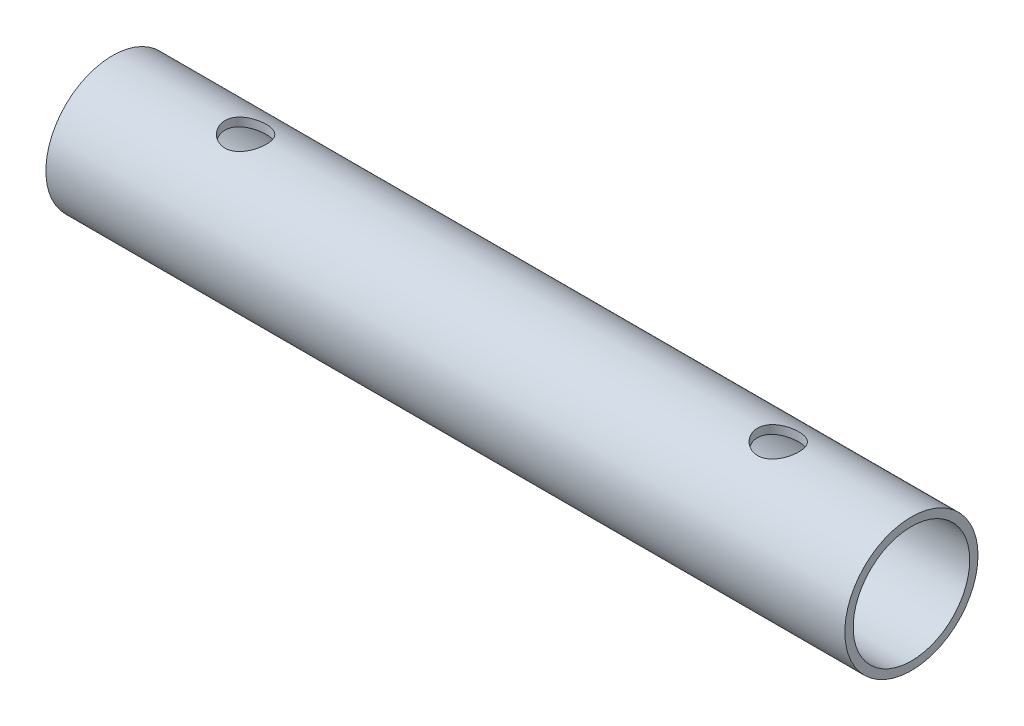
from build123d import *

# Parameters (mm, degrees)
SKETCH_1_R               = 10
SKETCH_1_R_2             = 8.75
EXTRUDE_1_DEPTH          = 120
SKETCH_2_R               = 3.1
CUT_EXTRUDE_1_DEPTH      = 11
CUT_EXTRUDE_1_DEPTH_BACK = 11


with BuildPart() as part:
    # 草图1 → 凸台-拉伸1 (new body)
    with BuildSketch(Plane(origin=(0, 0, 0), x_dir=(0, 0, -1), z_dir=(1, 0, 0))):
        Circle(SKETCH_1_R)
        Circle(SKETCH_1_R_2, mode=Mode.SUBTRACT)
    extrude(amount=EXTRUDE_1_DEPTH)

    # 草图2 → 切除-拉伸1 (cut, two sides)
    with BuildSketch(Plane(origin=(0, 0, 0), x_dir=(1, 0, 0), z_dir=(0, 1, 0))) as cut_extrude_1_sk:
        with Locations((20, 0)):
            Circle(SKETCH_2_R)
        with Locations((100, 0)):
            Circle(SKETCH_2_R)
    extrude(amount=CUT_EXTRUDE_1_DEPTH, mode=Mode.SUBTRACT)
    extrude(cut_extrude_1_sk.sketch, amount=-CUT_EXTRUDE_1_DEPTH_BACK, mode=Mode.SUBTRACT)


solid = part.part
